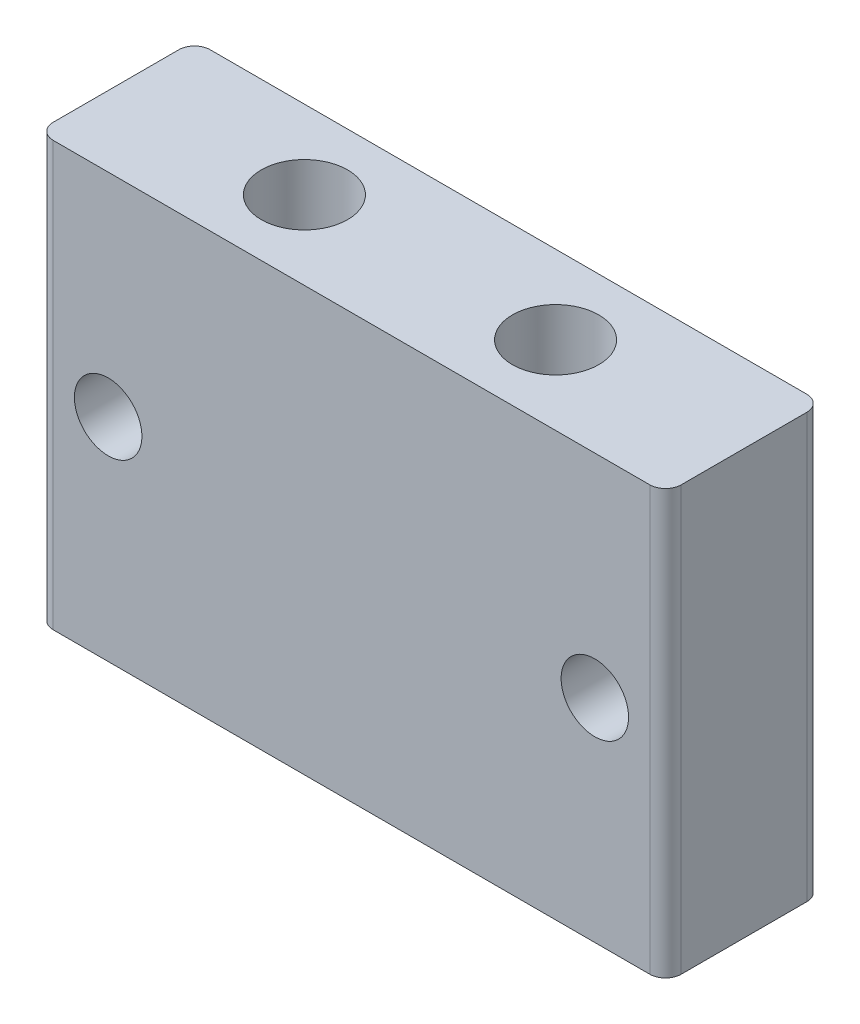
from build123d import *

# Parameters (mm, degrees)
SKETCH1_W               = 40
SKETCH1_H               = 10
BOSS_EXTRUDE1_DEPTH     = 27
SKETCH4_R               = 2.15
CUT_EXTRUDE1_DEPTH      = 1
CUT_EXTRUDE1_DEPTH_BACK = 11
FILLET1_R               = 1
SKETCH5_R               = 2.75
CUT_EXTRUDE2_DEPTH      = 1
CUT_EXTRUDE2_DEPTH_BACK = 28


with BuildPart() as part:
    # Sketch1 → Boss-Extrude1 (new body)
    with BuildSketch(Plane(origin=(0, 0, 0), x_dir=(1, 0, 0), z_dir=(0, 1, 0))):
        with Locations((20, 5)):
            Rectangle(SKETCH1_W, SKETCH1_H)
    extrude(amount=BOSS_EXTRUDE1_DEPTH)

    # Sketch4 → Cut-Extrude1 (cut, two sides)
    with BuildSketch(Plane(origin=(0, 0, -10), x_dir=(-1, 0, 0), z_dir=(0, 0, -1))) as cut_extrude1_sk:
        with Locations((-35.5, 13.5)):
            Circle(SKETCH4_R)
        with Locations((-4.5, 13.5)):
            Circle(SKETCH4_R)
    extrude(amount=CUT_EXTRUDE1_DEPTH, mode=Mode.SUBTRACT)
    extrude(cut_extrude1_sk.sketch, amount=-CUT_EXTRUDE1_DEPTH_BACK, mode=Mode.SUBTRACT)

    # Fillet1
    fillet1_edges = [part.edges().sort_by_distance(p)[0] for p in [
        (0, 13.5, -10),
        (40, 13.5, -10),
        (40, 13.5, 0),
        (0, 13.5, 0),
    ]]
    fillet(fillet1_edges, radius=FILLET1_R)

    # Sketch5 → Cut-Extrude2 (cut, two sides)
    with BuildSketch(Plane(origin=(0, 27, 0), x_dir=(1, 0, 0), z_dir=(0, 1, 0))) as cut_extrude2_sk:
        with Locations((12, 5)):
            Circle(SKETCH5_R)
        with Locations((28, 5)):
            Circle(SKETCH5_R)
    extrude(amount=CUT_EXTRUDE2_DEPTH, mode=Mode.SUBTRACT)
    extrude(cut_extrude2_sk.sketch, amount=-CUT_EXTRUDE2_DEPTH_BACK, mode=Mode.SUBTRACT)


solid = part.part
